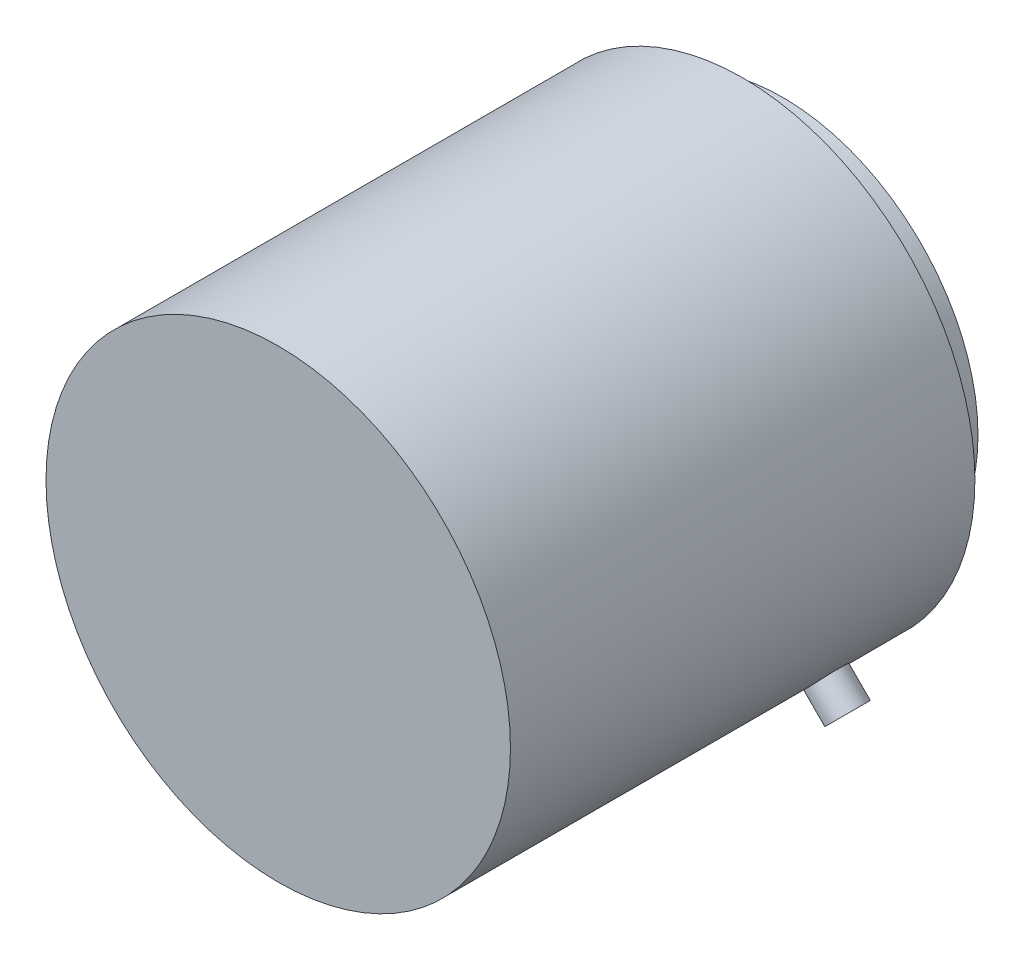
from build123d import *

# Parameters (mm, degrees)
SKETCH1_R               = 37.5
BOSS_EXTRUDE1_DEPTH     = 75
SKETCH2_R               = 31.5
BOSS_EXTRUDE2_DEPTH     = 6.5
SKETCH3_R               = 15.75
CUT_EXTRUDE1_DEPTH      = 6.5
SKETCH4_R               = 3
CUT_EXTRUDE2_DEPTH      = 5
BOSS_EXTRUDE3_START     = -10
BOSS_EXTRUDE3_DEPTH     = 6
CUT_EXTRUDE4_REACH      = 123.333
CUT_EXTRUDE4_END_RADIUS = 37.5
SKETCH7_R               = 7.955992876
SKETCH7_R_2             = 3


with BuildPart() as part:
    # Sketch1 → Boss-Extrude1 (new body)
    with BuildSketch(Plane.XY):
        Circle(SKETCH1_R)
    extrude(amount=BOSS_EXTRUDE1_DEPTH)

    # Sketch2 → Boss-Extrude2 (add)
    with BuildSketch(Plane(origin=(0, 0, 0), x_dir=(-1, 0, 0), z_dir=(0, 0, -1))):
        with Locations(Location((0, 0, 0), (0, 0, 180))):
            Circle(SKETCH2_R)
    extrude(amount=BOSS_EXTRUDE2_DEPTH)

    # Sketch3 → Cut-Extrude1 (cut)
    with BuildSketch(Plane(origin=(0, 0, -6.5), x_dir=(-1, 0, 0), z_dir=(0, 0, -1))):
        Circle(SKETCH3_R)
    extrude(amount=-CUT_EXTRUDE1_DEPTH, mode=Mode.SUBTRACT)

    # Sketch4 → Cut-Extrude2 (cut)
    with BuildSketch(Plane(origin=(0, 0, -6.5), x_dir=(-1, 0, 0), z_dir=(0, 0, -1))):
        with Locations((25, 0)):
            Circle(SKETCH4_R)
        with Locations((0, -25)):
            Circle(SKETCH4_R)
        with Locations((-25, 0)):
            Circle(SKETCH4_R)
        with Locations((0, 25)):
            Circle(SKETCH4_R)
    extrude(amount=-CUT_EXTRUDE2_DEPTH, mode=Mode.SUBTRACT)

    # Sketch6 → Boss-Extrude3 (add)
    with BuildSketch(Plane(origin=(0, 0, 0), x_dir=(-1, 0, 0), z_dir=(0, 0, -1)).offset(BOSS_EXTRUDE3_START)):
        with BuildLine():
            ThreePointArc((-24.310194937, -28.552835624), (-25.433737437, -27.556759606), (-26.516504294, -26.516504294))
            Line((-26.516504294, -26.516504294), (-29.941404236, -29.941404236))
            Line((-29.941404236, -29.941404236), (-27.820083892, -32.062724579))
            Line((-27.820083892, -32.062724579), (-24.310194936, -28.552835624))
        make_face()
        with BuildLine():
            Line((-29.941404236, -29.941404236), (-26.516504294, -26.516504294))
            ThreePointArc((-26.516504294, -26.516504294), (-27.556759606, -25.433737437), (-28.552835624, -24.310194937))
            Line((-28.552835624, -24.310194936), (-32.062724579, -27.820083892))
            Line((-32.062724579, -27.820083892), (-29.941404236, -29.941404236))
        make_face()
    extrude(amount=-BOSS_EXTRUDE3_DEPTH)

    # Cut-Extrude4: up to this cylinder (the profile starts outside it)
    cut_extrude4_end = Plane(origin=(0, 0, 20.730963), z_dir=(0, 0, -1)) * Cylinder(CUT_EXTRUDE4_END_RADIUS, 322.666, mode=Mode.PRIVATE)
    # Sketch7 → Cut-Extrude4 (cut, up to the surface)
    with BuildSketch(Plane(origin=(29.941404236, -29.941404236, 0), x_dir=(0, 0, -1), z_dir=(0.7071067811865471, -0.7071067811865479, 0)), mode=Mode.PRIVATE) as cut_extrude4_sk1:
        with Locations((-13, 0)):
            Circle(SKETCH7_R)
        with Locations(Location((-13, 0, 0), (0, 0, 90))):
            Circle(SKETCH7_R_2, mode=Mode.SUBTRACT)
    cut_extrude4_tool1 = extrude(cut_extrude4_sk1.sketch, amount=-CUT_EXTRUDE4_REACH, mode=Mode.PRIVATE) - cut_extrude4_end
    add(cut_extrude4_tool1.solids().sort_by_distance((29.941404, -29.941404, 20.730963))[0], mode=Mode.SUBTRACT)


solid = part.part
